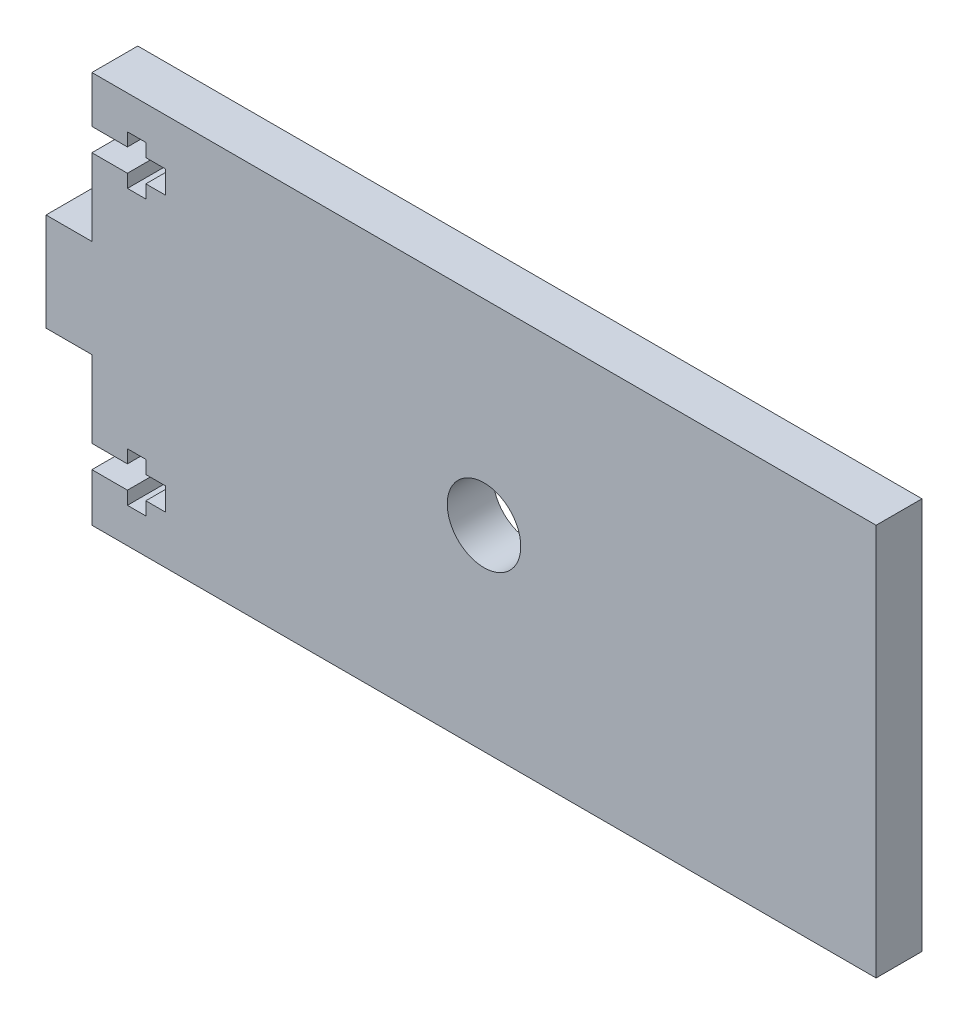
from build123d import *

# Parameters (mm, degrees)
SKETCH1_W           = 101.6
SKETCH1_H           = 50.8
BOSS_EXTRUDE1_DEPTH = 5.9436
SKETCH2_R           = 4.7625
CUT_EXTRUDE1_DEPTH  = 6.9436
SKETCH3_W           = 5.94334
SKETCH3_H           = 12.7
BOSS_EXTRUDE2_DEPTH = 5.9436
CUT_EXTRUDE2_DEPTH  = 6.9436


with BuildPart() as part:
    # Sketch1 → Boss-Extrude1 (new body)
    with BuildSketch(Plane.XY):
        with Locations((50.8, 25.4)):
            Rectangle(SKETCH1_W, SKETCH1_H)
    extrude(amount=BOSS_EXTRUDE1_DEPTH)

    # Sketch2 → Cut-Extrude1 (cut, through all)
    with BuildSketch(Plane.XY.offset(5.9436)):
        with Locations((50.8, 25.4)):
            Circle(SKETCH2_R)
    extrude(amount=-CUT_EXTRUDE1_DEPTH, mode=Mode.SUBTRACT)

    # Sketch3 → Boss-Extrude2 (add)
    with BuildSketch(Plane(origin=(0, 0, 0), x_dir=(-1, 0, 0), z_dir=(0, 0, -1))):
        with Locations((2.97167, 25.492131347)):
            Rectangle(SKETCH3_W, SKETCH3_H)
    extrude(amount=-BOSS_EXTRUDE2_DEPTH)

    # Sketch5 → Cut-Extrude2 (cut, through all)
    with BuildSketch(Plane(origin=(0, 0, 0), x_dir=(-1, 0, 0), z_dir=(0, 0, -1))):
        Polygon((0, 41.798931347), (-4.60401, 41.798931347), (-4.60401, 40.097131347), (-6.98526, 40.097131347), (-6.98526, 41.798931347), (-9.52526, 41.798931347), (-9.52526, 44.745331347), (-6.98526, 44.745331347), (-6.98526, 46.447131347), (-4.60401, 46.447131347), (-4.60401, 44.745331347), (0, 44.745331347), align=None)
        Polygon((-4.60401, 4.537131347), (-4.60401, 6.238931347), (0, 6.238931347), (0, 9.185331347), (-4.60401, 9.185331347), (-4.60401, 10.887131347), (-6.98526, 10.887131347), (-6.98526, 9.185331347), (-9.52526, 9.185331347), (-9.52526, 6.238931347), (-6.98526, 6.238931347), (-6.98526, 4.537131347), align=None)
    extrude(amount=-CUT_EXTRUDE2_DEPTH, mode=Mode.SUBTRACT)


solid = part.part
